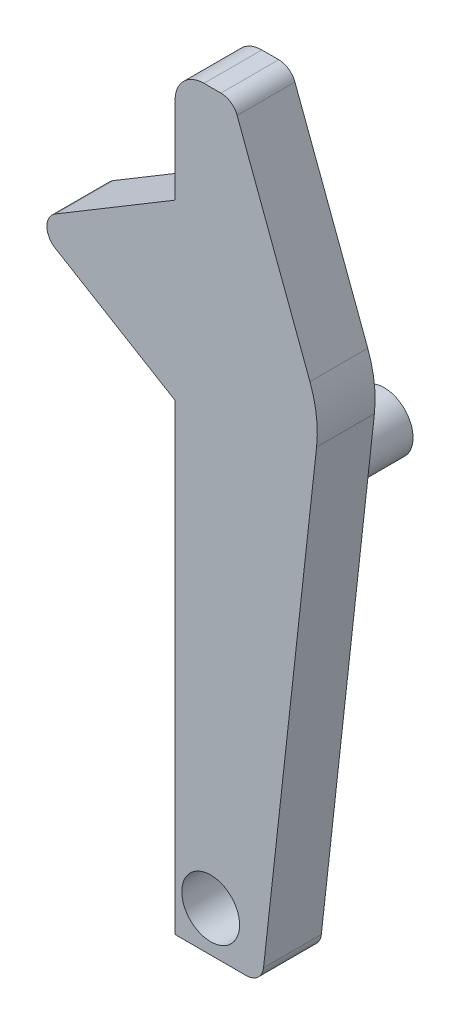
from build123d import *

# Parameters (mm, degrees)
SALIENTE_EXTRUIR1_DEPTH = 0.5
CROQUIS3_R              = 0.25
SALIENTE_EXTRUIR3_DEPTH = 1
CORTAR_EXTRUIR1_REACH   = 2.5
CROQUIS2_R              = 0.25


with BuildPart() as part:
    # Croquis1 → Saliente-Extruir1 (new body)
    with BuildSketch(Plane.XY):
        with BuildLine():
            Line((0.306789568, 2.029895733), (0.936329178, 0.351123442))
            ThreePointArc((0.936329178, 0.351123442), (0.992314828, 0.123738762), (0.993883735, -0.110431526))
            Line((0.993883735, -0.110431526), (0.535116403, -4.239337512))
            ThreePointArc((0.535116403, -4.239337512), (0.486072062, -4.334541985), (0.386033843, -4.372772783))
            Line((0.386033843, -4.372772783), (-0.229709738, -4.372772783))
            Line((-0.229709738, -4.372772783), (-0.229709738, -0.372772783))
            Line((-0.229709738, -0.372772783), (-1.265336507, 0.248603278))
            ThreePointArc((-1.265336507, 0.248603278), (-1.338162144, 0.377227217), (-1.265336507, 0.505851156))
            Line((-1.265336507, 0.505851156), (-0.229709738, 1.127227217))
            Line((-0.229709738, 1.127227217), (-0.229709738, 1.877227217))
            ThreePointArc((-0.229709738, 1.877227217), (-0.156486434, 2.054003913), (0.020290262, 2.127227217))
            Line((0.020290262, 2.127227217), (0.166340191, 2.127227217))
            ThreePointArc((0.166340191, 2.127227217), (0.251779417, 2.10051606), (0.306789568, 2.029895733))
        make_face()
    extrude(amount=SALIENTE_EXTRUIR1_DEPTH)

    # Croquis3 → Saliente-Extruir3 (add)
    with BuildSketch(Plane(origin=(0, 0, 0), x_dir=(-1, 0, 0), z_dir=(0, 0, -1))):
        with Locations((-0.078162052, -1.122772783)):
            Circle(CROQUIS3_R)
    extrude(amount=SALIENTE_EXTRUIR3_DEPTH)

    # Croquis2 → Cortar-Extruir1 (cut, up to next)
    with BuildSketch(Plane(origin=(0, 0, 0), x_dir=(-1, 0, 0), z_dir=(0, 0, -1)), mode=Mode.PRIVATE) as cortar_extruir1_sk1:
        with Locations((-0.078162052, -4.022772783)):
            Circle(CROQUIS2_R)
    cortar_extruir1_tool1 = extrude(cortar_extruir1_sk1.sketch, amount=-CORTAR_EXTRUIR1_REACH, mode=Mode.PRIVATE) & part.part
    add(cortar_extruir1_tool1.solids().sort_by_distance((0.078162, -4.022773, 0))[0], mode=Mode.SUBTRACT)


solid = part.part
